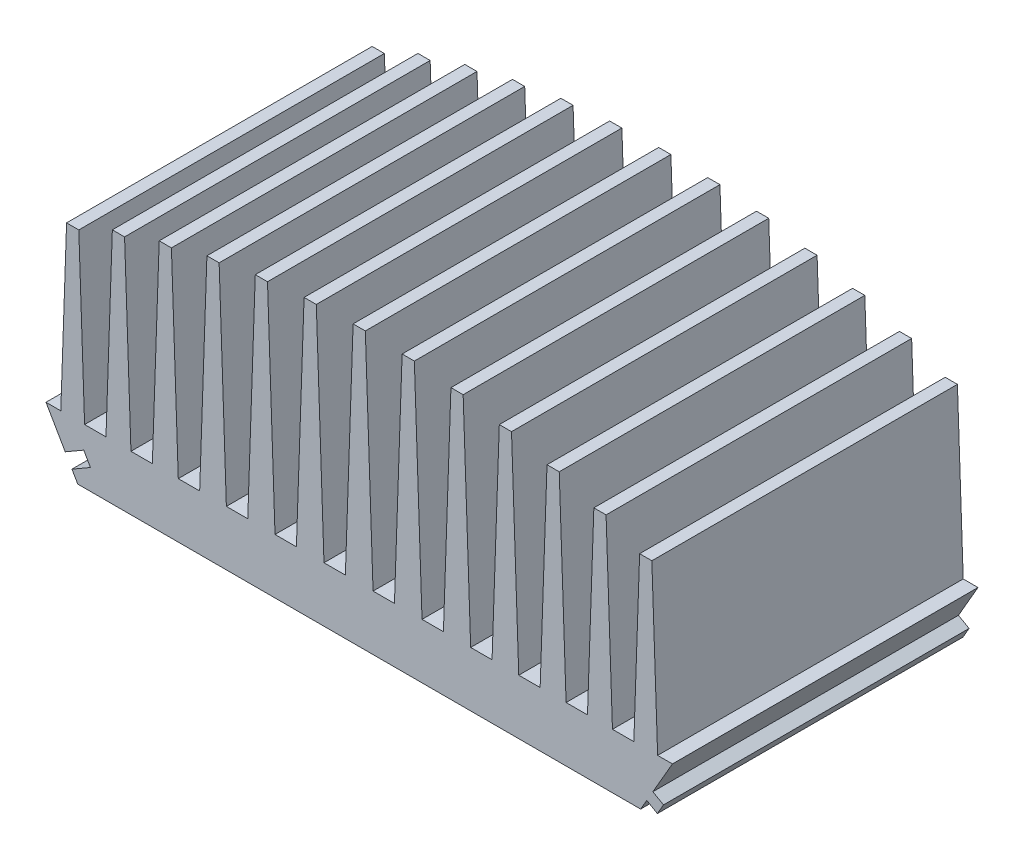
from build123d import *

# Parameters (mm, degrees)
RESSALTO_EXTRUS_O1_DEPTH    = 285
CORTE_EXTRUS_O1_DEPTH       = 286
RESSALTO_EXTRUS_O3_DEPTH    = 285
ESBO_O13_W                  = 1.5
ESBO_O13_H                  = 2
CORTE_EXTRUS_O7_DEPTH       = 52.25
CORTE_EXTRUS_O7_DEPTH_BACK  = 52.25
RESSALTO_EXTRUS_O5_DEPTH    = 10
ESBO_O5_R                   = 1.25
CORTE_EXTRUS_O3_DEPTH       = 10
ESBO_O6_W                   = 10
ESBO_O6_H                   = 6.190700041
RESSALTO_EXTRUS_O4_DEPTH    = 11
ESBO_O7_R                   = 2.25
CORTE_EXTRUS_O4_DEPTH       = 12
ESBO_O9_R                   = 1.65
CORTE_EXTRUS_O5_DEPTH       = 10
RESSALTO_EXTRUS_O6_DEPTH    = 15
ESBO_O12_R                  = 2.5
CORTE_EXTRUS_O8_DEPTH       = 20
CORTE_EXTRUS_O9_START       = -11
ESBO_O14_R                  = 6
CORTE_EXTRUS_O9_DEPTH       = 100
PADR_O_LINEAR1_COUNT        = 2
PADR_O_LINEAR1_PITCH        = 230
ESBO_O16_W                  = 118.931950447
ESBO_O16_H                  = 98.407051197
ESBO_O16_W_2                = 168.047643727
ESBO_O16_H_2                = 92.783791129
CORTE_EXTRUS_O11_DEPTH      = 55.553847577
CORTE_EXTRUS_O11_DEPTH_BACK = 55.603847577


with BuildPart() as part:
    # Esboço1 → Ressalto-extrusão1 (new body)
    with BuildSketch(Plane.XY):
        Polygon((-46.053847577, 79.767603888), (-51.25, 88.767603888), (-48.82913331, 88.767603888), (-47.882520117, 115.87505904), (-45.882520117, 115.87505904), (-44.935906924, 88.767603888), (-41.435906924, 88.767603888), (-40.393073045, 118.630458973), (-38.393073045, 118.630458973), (-37.350239166, 88.767603888), (-33.850239166, 88.767603888), (-32.727930438, 120.906320886), (-30.727930438, 120.906320886), (-29.60562171, 88.767603888), (-26.10562171, 88.767603888), (-24.921032923, 122.689788425), (-22.921032923, 122.689788425), (-21.736444137, 88.767603888), (-18.236444137, 88.767603888), (-17.007119627, 123.970851902), (-15.007119627, 123.970851902), (-13.777795118, 88.767603888), (-10.277795118, 88.767603888), (-9.021529135, 124.742354757), (-7.021529135, 124.742354757), (-5.765263153, 88.767603888), (-2.265263153, 88.767603888), (-1, 125), (1, 125), (2.265263153, 88.767603888), (5.765263153, 88.767603888), (7.021529135, 124.742354757), (9.021529135, 124.742354757), (10.277795118, 88.767603888), (13.777795118, 88.767603888), (15.007119627, 123.970851902), (17.007119627, 123.970851902), (18.236444137, 88.767603888), (21.736444137, 88.767603888), (22.921032923, 122.689788425), (24.921032923, 122.689788425), (26.10562171, 88.767603888), (29.60562171, 88.767603888), (30.727930438, 120.906320886), (32.727930438, 120.906320886), (33.850239166, 88.767603888), (37.350239166, 88.767603888), (38.393073045, 118.630458973), (40.393073045, 118.630458973), (41.435906924, 88.767603888), (44.935906924, 88.767603888), (45.882520117, 115.87505904), (47.882520117, 115.87505904), (48.82913331, 88.767603888), (51.25, 88.767603888), (46.053847577, 79.767603888), align=None)
    extrude(amount=RESSALTO_EXTRUS_O1_DEPTH)

    # Esboço2 → Corte-extrusão1 (cut, through all)
    with BuildSketch(Plane.XY.offset(285)):
        Polygon((-47.003847577, 81.413052155), (-43.972758664, 83.163052155), (-45.072758664, 85.068308043), (-48.103847577, 83.318308043), align=None)
    extrude(amount=-CORTE_EXTRUS_O1_DEPTH, mode=Mode.SUBTRACT)


with BuildPart() as body_2:
    # Esboço3 → Ressalto-extrusão3 (new body)
    with BuildSketch(Plane.XY.offset(285)):
        Polygon((47.053847577, 81.499654695), (48.053847577, 83.231705503), (49.785898385, 82.231705503), (48.785898385, 80.499654695), align=None)
    extrude(amount=-RESSALTO_EXTRUS_O3_DEPTH)


with BuildPart() as corte_extrus_o7_tool:
    # Esboço13 → Corte-extrusão7 (new body, two sides)
    with BuildSketch(Plane(origin=(0, 0, 0), x_dir=(0, 0, -1), z_dir=(1, 0, 0))) as corte_extrus_o7_sk:
        with Locations((-284.25, 82.767603888)):
            Rectangle(ESBO_O13_W, ESBO_O13_H)
    extrude(amount=CORTE_EXTRUS_O7_DEPTH)
    extrude(corte_extrus_o7_sk.sketch, amount=-CORTE_EXTRUS_O7_DEPTH_BACK)


with BuildPart() as part_1:
    add(part.part)

    # Corte-extrusão7: cut by corte_extrus_o7_tool
    add(corte_extrus_o7_tool.part, mode=Mode.SUBTRACT)



with BuildPart() as body_2_1:
    add(body_2.part)

    # Corte-extrusão7: cut by corte_extrus_o7_tool
    add(corte_extrus_o7_tool.part, mode=Mode.SUBTRACT)


with BuildPart() as part_2:
    add(part_1.part)

    add(body_2_1.part)  # Ressalto-extrusão5 merges body 2
    # Esboço8 → Ressalto-extrusão5 (add)
    with BuildSketch(Plane(origin=(0, 0, 0), x_dir=(0, 0, -1), z_dir=(0.866025404, -0.5, 0))):
        with BuildLine():
            Line((-280, 104.107695155), (-280, 96.107695155))
            Line((-280, 96.107695155), (-270, 96.107695155))
            Line((-270, 96.107695155), (-270, 104.107695155))
            ThreePointArc((-270, 104.107695155), (-275, 109.107695155), (-280, 104.107695155))
        make_face()
    ressalto_extrus_o5 = extrude(amount=-RESSALTO_EXTRUS_O5_DEPTH)

    # Esboço5 → Corte-extrusão3 (cut)
    with BuildSketch(Plane.XY.offset(285)):
        with Locations((-30, 85.267603888)):
            Circle(ESBO_O5_R)
        with Locations((30, 85.267603888)):
            Circle(ESBO_O5_R)
    extrude(amount=-CORTE_EXTRUS_O3_DEPTH, mode=Mode.SUBTRACT)

    # Esboço6 → Ressalto-extrusão4 (add)
    with BuildSketch(Plane(origin=(0, 0, 0), x_dir=(0, 0, 1), z_dir=(-0.866025404, -0.5, 0))):
        with BuildLine():
            Line((280, 102.5), (280, 104.207693629))
            ThreePointArc((280, 104.207693629), (275, 109.207695155), (270, 104.207693629))
            Line((270, 104.207693629), (270, 102.5))
            Line((270, 102.5), (280, 102.5))
        make_face()
        with Locations((275, 99.404649979)):
            Rectangle(ESBO_O6_W, ESBO_O6_H)
    ressalto_extrus_o4 = extrude(amount=-RESSALTO_EXTRUS_O4_DEPTH)

    # Esboço7 → Corte-extrusão4 (cut)
    with BuildSketch(Plane(origin=(0, 0, 0), x_dir=(0, 0, 1), z_dir=(-0.866025404, -0.5, 0))):
        with Locations((275, 104.207695155)):
            Circle(ESBO_O7_R)
    corte_extrus_o4 = extrude(amount=-CORTE_EXTRUS_O4_DEPTH, mode=Mode.SUBTRACT)

    # Esboço9 → Corte-extrusão5 (cut)
    with BuildSketch(Plane(origin=(0, 0, 0), x_dir=(0, 0, -1), z_dir=(0.866025404, -0.5, 0))):
        with Locations((-275, 104.107695155)):
            Circle(ESBO_O9_R)
    corte_extrus_o5 = extrude(amount=-CORTE_EXTRUS_O5_DEPTH, mode=Mode.SUBTRACT)

    # Esboço10 → Ressalto-extrusão6 (add)
    with BuildSketch(Plane(origin=(0, 0, 0), x_dir=(-1, 0, 0), z_dir=(0, 0, -1))):
        Polygon((5.765263153, 88.767603888), (6.680885729, 114.987603888), (1.349640577, 114.987603888), (2.265263153, 88.767603888), align=None)
        Polygon((-2.265263153, 88.767603888), (-1.349640577, 114.987603888), (-6.680885729, 114.987603888), (-5.765263153, 88.767603888), align=None)
    extrude(amount=-RESSALTO_EXTRUS_O6_DEPTH)

    # Esboço12 → Corte-extrusão8 (cut)
    with BuildSketch(Plane(origin=(0, 0, 0), x_dir=(-1, 0, 0), z_dir=(0, 0, -1))):
        with Locations((0, 104.999999962)):
            Circle(ESBO_O12_R)
    extrude(amount=-CORTE_EXTRUS_O8_DEPTH, mode=Mode.SUBTRACT)

    # Esboço14 → Corte-extrusão9 (cut)
    with BuildSketch(Plane(origin=(0, 0, 0), x_dir=(0, 0, 1), z_dir=(-0.866025404, -0.5, 0)).offset(CORTE_EXTRUS_O9_START)):
        with Locations((275, 104.207695155)):
            Circle(ESBO_O14_R)
    corte_extrus_o9 = extrude(amount=-CORTE_EXTRUS_O9_DEPTH, mode=Mode.SUBTRACT)

    # Padrão linear1: Ressalto-extrusão5, Ressalto-extrusão4, Corte-extrusão4, Corte-extrusão5, Corte-extrusão9 ×2
    with Locations(*[(0, 0, -i * PADR_O_LINEAR1_PITCH) for i in range(1, PADR_O_LINEAR1_COUNT)]):
        add(ressalto_extrus_o5)
        add(ressalto_extrus_o4)
        add(corte_extrus_o4, mode=Mode.SUBTRACT)
        add(corte_extrus_o5, mode=Mode.SUBTRACT)
        add(corte_extrus_o9, mode=Mode.SUBTRACT)

    # Esboço16 → Corte-extrusão11 (cut, two sides)
    with BuildSketch(Plane(origin=(0, 0, 0), x_dir=(0, 0, -1), z_dir=(1, 0, 0))) as corte_extrus_o11_sk:
        with Locations((-250.695007134, 104.881737693)):
            Rectangle(ESBO_O16_W, ESBO_O16_H)
        with Locations((-57.205210046, 102.070107659)):
            Rectangle(ESBO_O16_W_2, ESBO_O16_H_2)
    extrude(amount=CORTE_EXTRUS_O11_DEPTH, mode=Mode.SUBTRACT)
    extrude(corte_extrus_o11_sk.sketch, amount=-CORTE_EXTRUS_O11_DEPTH_BACK, mode=Mode.SUBTRACT)


solid = part_2.part
